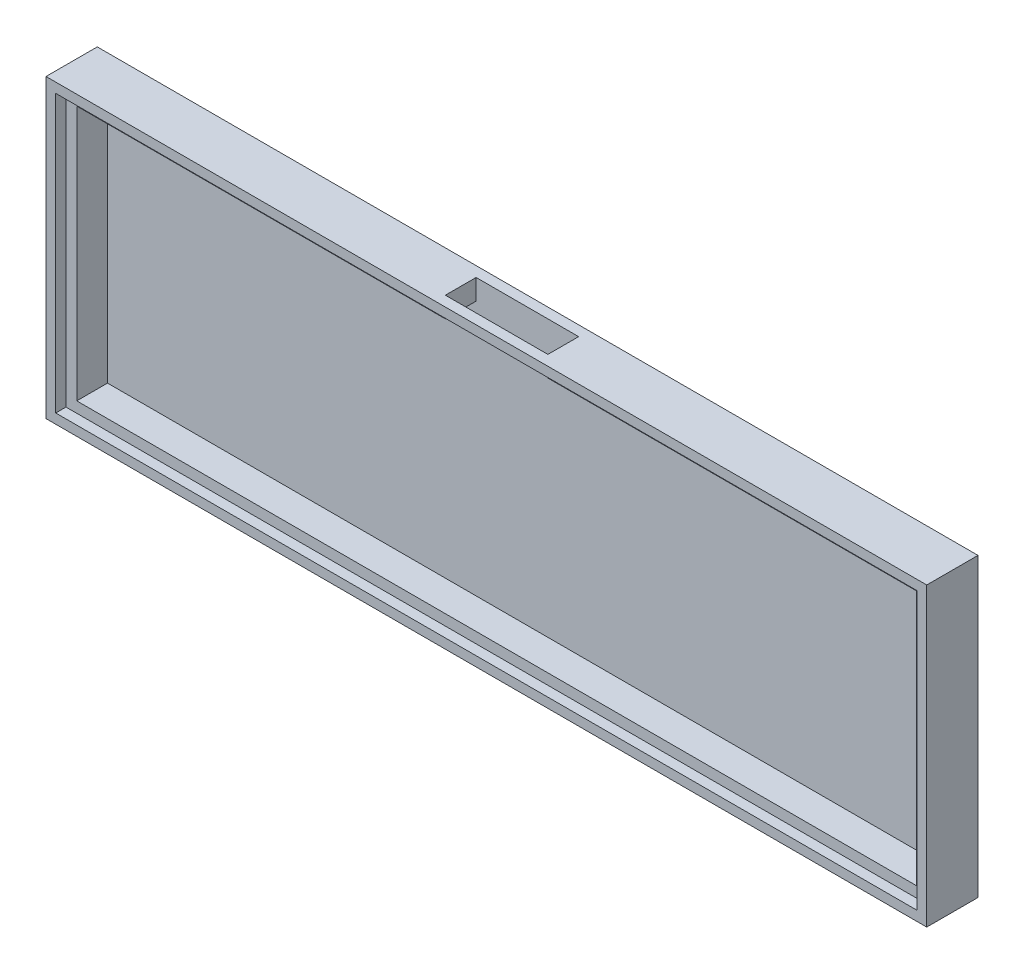
from build123d import *

# Parameters (mm, degrees)
SKETCH1_W               = 171.8
SKETCH1_H               = 57.8
MAIN_BODY_DEPTH         = 10
SKETCH2_W               = 163.8
SKETCH2_H               = 49.8
MAIN_CUTOUT_DEPTH       = 8
SKETCH3_W               = 6
SKETCH3_H               = 20
CABLE_PASSTHROUGH_DEPTH = 4
SKETCH9_W               = 168
SKETCH9_H               = 54
LID_CUTOUT_DEPTH        = 2


with BuildPart() as part:
    # Sketch1 → Main_Body (new body)
    with BuildSketch(Plane.XY):
        with Locations((85.9, 28.9)):
            Rectangle(SKETCH1_W, SKETCH1_H)
    extrude(amount=MAIN_BODY_DEPTH)

    # Sketch2 → Main_Cutout (cut)
    with BuildSketch(Plane.XY.offset(10)):
        with Locations((85.9, 28.9)):
            Rectangle(SKETCH2_W, SKETCH2_H)
    extrude(amount=-MAIN_CUTOUT_DEPTH, mode=Mode.SUBTRACT)

    # Sketch3 → Cable_Passthrough (cut)
    with BuildSketch(Plane(origin=(53.8, 57.8, 0), x_dir=(0, 0, 1), z_dir=(0, -1, 0))):
        with Locations((5, -32.1)):
            Rectangle(SKETCH3_W, SKETCH3_H)
    extrude(amount=CABLE_PASSTHROUGH_DEPTH, mode=Mode.SUBTRACT)

    # Sketch9 → Lid_Cutout (cut)
    with BuildSketch(Plane.XY.offset(10)):
        with Locations((85.9, 28.9)):
            Rectangle(SKETCH9_W, SKETCH9_H)
    extrude(amount=-LID_CUTOUT_DEPTH, mode=Mode.SUBTRACT)


solid = part.part
